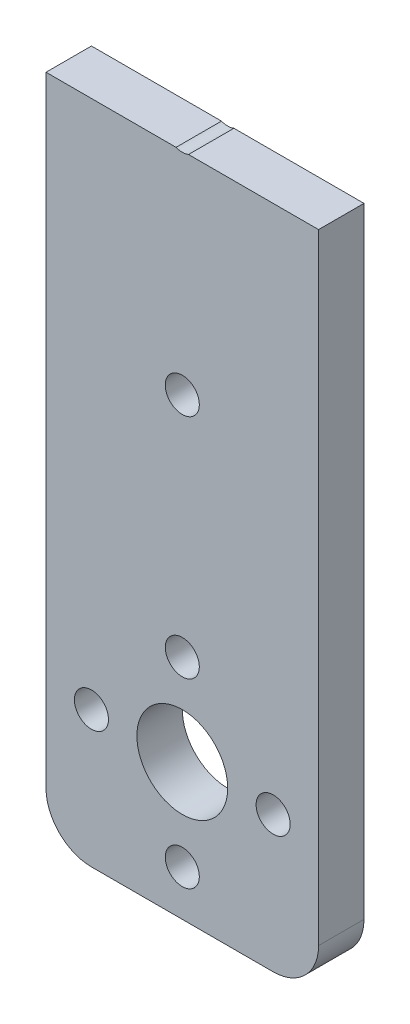
from build123d import *

# Parameters (mm, degrees)
SKETCH1_W           = 24
SKETCH1_H           = 80
BOSS_EXTRUDE1_DEPTH = 4
SKETCH2_R           = 4
SKETCH2_R_2         = 1.5
CUT_EXTRUDE1_DEPTH  = 4
FILLET1_R           = 4
SKETCH3_R           = 1.5
CUT_EXTRUDE2_DEPTH  = 4
SKETCH4_W           = 24
SKETCH4_H           = 21.396683756
CUT_EXTRUDE3_DEPTH  = 4


with BuildPart() as part:
    # Sketch1 → Boss-Extrude1 (new body)
    with BuildSketch(Plane.XY):
        with Locations((-45.296675466, -5.049681021)):
            Rectangle(SKETCH1_W, SKETCH1_H)
    extrude(amount=BOSS_EXTRUDE1_DEPTH)

    # Sketch2 → Cut-Extrude1 (cut)
    with BuildSketch(Plane.XY.offset(4)):
        with Locations((-45.296675466, -33.049681021)):
            Circle(SKETCH2_R)
        with Locations((-37.296675466, -33.049681021)):
            Circle(SKETCH2_R_2)
        with Locations((-45.296675466, -41.049681021)):
            Circle(SKETCH2_R_2)
        with Locations((-53.296675466, -33.049681021)):
            Circle(SKETCH2_R_2)
        with Locations((-45.296675466, -25.049681021)):
            Circle(SKETCH2_R_2)
        with Locations((-45.296675466, 30.950318979)):
            Circle(SKETCH2_R_2)
        with Locations((-37.296675466, 22.950318979)):
            Circle(SKETCH2_R_2)
        with Locations((-45.296675466, 14.950318979)):
            Circle(SKETCH2_R_2)
        with Locations((-53.296675466, 22.950318979)):
            Circle(SKETCH2_R_2)
        with Locations((-45.296675466, 22.950318979)):
            Circle(SKETCH2_R)
    extrude(amount=-CUT_EXTRUDE1_DEPTH, mode=Mode.SUBTRACT)

    # Fillet1
    fillet1_edges = [part.edges().sort_by_distance(p)[0] for p in [
        (-57.296675466, 34.950318979, 2),
        (-57.296675466, -45.049681021, 2),
        (-33.296675466, -45.049681021, 2),
        (-33.296675466, 34.950318979, 2),
    ]]
    fillet(fillet1_edges, radius=FILLET1_R)

    # Sketch3 → Cut-Extrude2 (cut)
    with BuildSketch(Plane.XY.offset(4)):
        with Locations((-45.296675466, -5.049681021)):
            Circle(SKETCH3_R)
    extrude(amount=-CUT_EXTRUDE2_DEPTH, mode=Mode.SUBTRACT)

    # Sketch4 → Cut-Extrude3 (cut)
    with BuildSketch(Plane.XY.offset(4)):
        with Locations((-45.296675466, 24.251977101)):
            Rectangle(SKETCH4_W, SKETCH4_H)
    extrude(amount=-CUT_EXTRUDE3_DEPTH, mode=Mode.SUBTRACT)


solid = part.part
